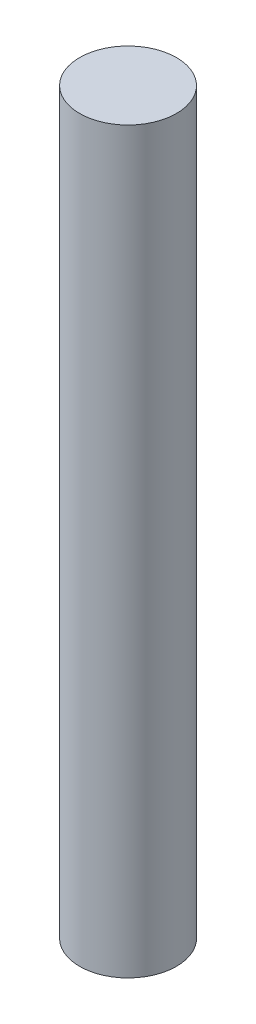
from build123d import *

# Parameters (mm, degrees)
SKETCH1_W = 2
SKETCH1_H = 30.5


with BuildPart() as part:
    # Sketch1 → Revolve1 (revolve)
    with BuildSketch(Plane.XY):
        with Locations((1, 0)):
            Rectangle(SKETCH1_W, SKETCH1_H)
    revolve(axis=Axis((0, 0, 0), (0, 1, 0)))


solid = part.part
